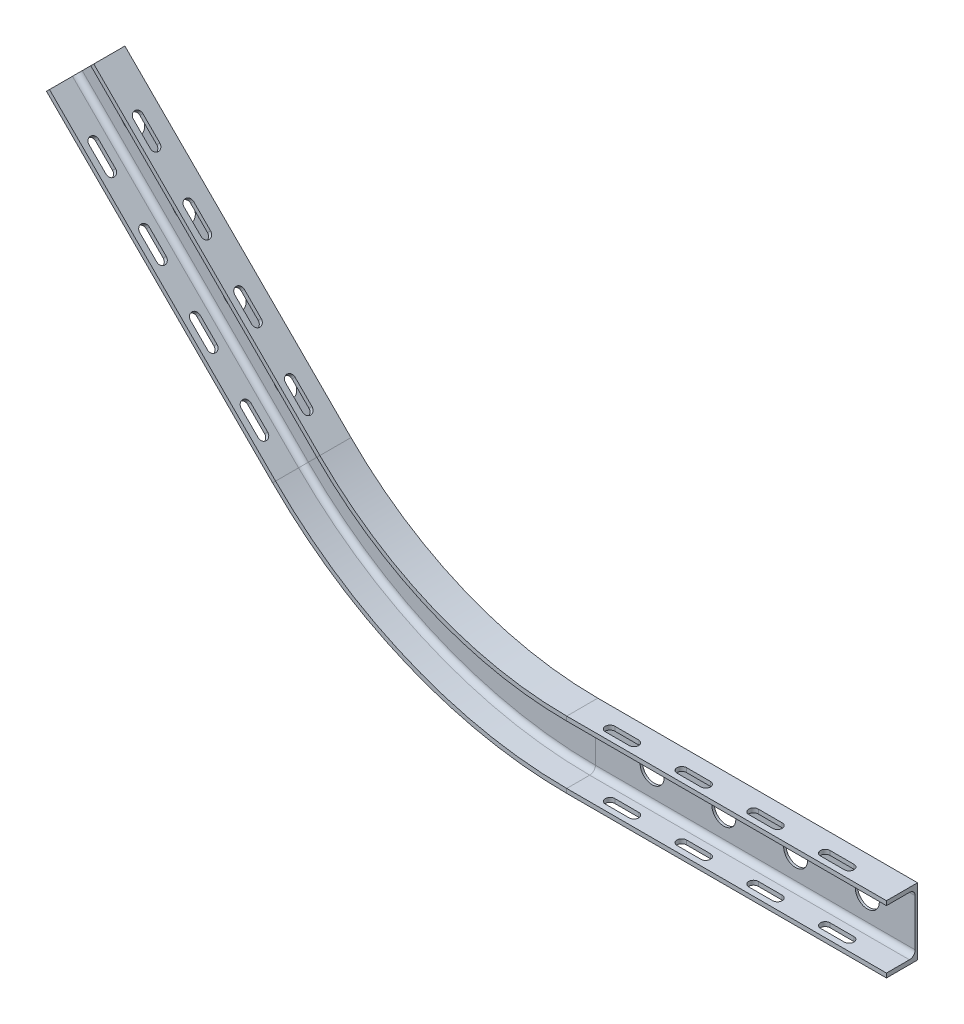
from build123d import *

# Parameters (mm, degrees)
UPE_UPE_140_1_DEPTH     = 668.629150102
UPE_UPE_140_1_2_ANGLE   = 45
UPE_UPE_140_1_3_DEPTH   = 668.629150102
ENL_V_MAT_EXTRU_1_DEPTH = 655.497474683
ENL_V_MAT_EXTRU_2_DEPTH = 141
ESQUISSE5_R             = 25
ENL_V_MAT_EXTRU_3_DEPTH = 6


with BuildPart() as part:
    # Skizze1 → Upe UPE 140(1) (new body)
    with BuildSketch(Plane(origin=(-707.106781187, 707.106781187, 0), x_dir=(0.707106781, 0.707106781, 0), z_dir=(0.707106781, -0.707106781, 0))):
        with BuildLine():
            Line((-70, 65), (-61, 65))
            Line((-61, 65), (-61, 17))
            ThreePointArc((-61, 17), (-57.485281374, 8.514718626), (-49, 5))
            Line((-49, 5), (49, 5))
            ThreePointArc((49, 5), (57.485281374, 8.514718626), (61, 17))
            Line((61, 17), (61, 65))
            Line((61, 65), (70, 65))
            Line((70, 65), (70, 0))
            Line((70, 0), (-70, 0))
            Line((-70, 0), (-70, 65))
        make_face()
    extrude(amount=UPE_UPE_140_1_DEPTH)

    # Esquisse3 → Enlèv. mat.-Extru.1 (cut, through all)
    with BuildSketch(Plane(origin=(49.497474683, 49.497474683, 0), x_dir=(0, 0, -1), z_dir=(0.707106781, 0.707106781, 0))):
        with BuildLine():
            Line((-33, 900), (-33, 850))
            ThreePointArc((-33, 850), (-43, 840), (-53, 850))
            Line((-53, 850), (-53, 900))
            ThreePointArc((-53, 900), (-43, 910), (-33, 900))
        make_face()
        with BuildLine():
            Line((-33, 750), (-33, 700))
            ThreePointArc((-33, 700), (-43, 690), (-53, 700))
            Line((-53, 700), (-53, 750))
            ThreePointArc((-53, 750), (-43, 760), (-33, 750))
        make_face()
        with BuildLine():
            Line((-33, 600), (-33, 550))
            ThreePointArc((-33, 550), (-43, 540), (-53, 550))
            Line((-53, 550), (-53, 600))
            ThreePointArc((-53, 600), (-43, 610), (-33, 600))
        make_face()
        with BuildLine():
            Line((-33, 450), (-33, 400))
            ThreePointArc((-33, 400), (-43, 390), (-53, 400))
            Line((-53, 400), (-53, 450))
            ThreePointArc((-53, 450), (-43, 460), (-33, 450))
        make_face()
    extrude(amount=-ENL_V_MAT_EXTRU_1_DEPTH, mode=Mode.SUBTRACT)


with BuildPart() as body_2:
    # Skizze1 on segment 2 (carried to the start of arc 2) → Upe UPE 140_1 2 (revolve)
    with BuildSketch(Plane(origin=(-234.314575051, 234.314575051, 0), x_dir=(0.707106781, 0.707106781, 0), z_dir=(0.707106781, -0.707106781, 0))):
        with BuildLine():
            Line((-70, 65), (-61, 65))
            Line((-61, 65), (-61, 17))
            ThreePointArc((-61, 17), (-57.485281374, 8.514718626), (-49, 5))
            Line((-49, 5), (49, 5))
            ThreePointArc((49, 5), (57.485281374, 8.514718626), (61, 17))
            Line((61, 17), (61, 65))
            Line((61, 65), (70, 65))
            Line((70, 65), (70, 0))
            Line((70, 0), (-70, 0))
            Line((-70, 0), (-70, 65))
        make_face()
    revolve(axis=Axis((331.370849898, 800, 0), (0, 0, 1)), revolution_arc=UPE_UPE_140_1_2_ANGLE)


with BuildPart() as body_3:
    # Skizze1 on segment 3 (carried to segment 3) → Upe UPE 140_1 3 (new body)
    with BuildSketch(Plane.YZ.offset(331.370849898)):
        with BuildLine():
            Line((-70, 65), (-61, 65))
            Line((-61, 65), (-61, 17))
            ThreePointArc((-61, 17), (-57.485281374, 8.514718626), (-49, 5))
            Line((-49, 5), (49, 5))
            ThreePointArc((49, 5), (57.485281374, 8.514718626), (61, 17))
            Line((61, 17), (61, 65))
            Line((61, 65), (70, 65))
            Line((70, 65), (70, 0))
            Line((70, 0), (-70, 0))
            Line((-70, 0), (-70, 65))
        make_face()
    extrude(amount=UPE_UPE_140_1_3_DEPTH)

    # Esquisse4 → Enlèv. mat.-Extru.2 (cut, through all)
    with BuildSketch(Plane(origin=(0, 70, 0), x_dir=(1, 0, 0), z_dir=(0, 1, 0))):
        with BuildLine():
            Line((900, -53), (850, -53))
            ThreePointArc((850, -53), (840, -43), (850, -33))
            Line((850, -33), (900, -33))
            ThreePointArc((900, -33), (910, -43), (900, -53))
        make_face()
        with BuildLine():
            Line((750, -53), (700, -53))
            ThreePointArc((700, -53), (690, -43), (700, -33))
            Line((700, -33), (750, -33))
            ThreePointArc((750, -33), (760, -43), (750, -53))
        make_face()
        with BuildLine():
            Line((600, -53), (550, -53))
            ThreePointArc((550, -53), (540, -43), (550, -33))
            Line((550, -33), (600, -33))
            ThreePointArc((600, -33), (610, -43), (600, -53))
        make_face()
        with BuildLine():
            Line((450, -53), (400, -53))
            ThreePointArc((400, -53), (390, -43), (400, -33))
            Line((400, -33), (450, -33))
            ThreePointArc((450, -33), (460, -43), (450, -53))
        make_face()
    extrude(amount=-ENL_V_MAT_EXTRU_2_DEPTH, mode=Mode.SUBTRACT)


with BuildPart() as enl_v_mat_extru_3_tool:
    # Esquisse5 → Enlèv. mat.-Extru.3 (new body, through all)
    with BuildSketch(Plane.XY.offset(5)):
        with Locations((-636.396103068, 636.396103068)):
            Circle(ESQUISSE5_R)
        with Locations((-530.33008589, 530.33008589)):
            Circle(ESQUISSE5_R)
        with Locations((-424.264068712, 424.264068712)):
            Circle(ESQUISSE5_R)
        with Locations((-318.198051534, 318.198051534)):
            Circle(ESQUISSE5_R)
        with Locations(Location((900, 0, 0), (0, 0, 180))):  # turned: the seam where the file's is
            Circle(ESQUISSE5_R)
        with Locations(Location((750, 0, 0), (0, 0, 180))):  # turned: the seam where the file's is
            Circle(ESQUISSE5_R)
        with Locations(Location((600, 0, 0), (0, 0, 180))):  # turned: the seam where the file's is
            Circle(ESQUISSE5_R)
        with Locations(Location((450, 0, 0), (0, 0, 180))):  # turned: the seam where the file's is
            Circle(ESQUISSE5_R)
    extrude(amount=-ENL_V_MAT_EXTRU_3_DEPTH)


with BuildPart() as part_1:
    add(part.part)

    # Enlèv. mat.-Extru.3: cut by enl_v_mat_extru_3_tool
    add(enl_v_mat_extru_3_tool.part, mode=Mode.SUBTRACT)


with BuildPart() as body_3_1:
    add(body_3.part)

    # Enlèv. mat.-Extru.3: cut by enl_v_mat_extru_3_tool
    add(enl_v_mat_extru_3_tool.part, mode=Mode.SUBTRACT)


solid = Compound([body_2.part, part_1.part, body_3_1.part])
